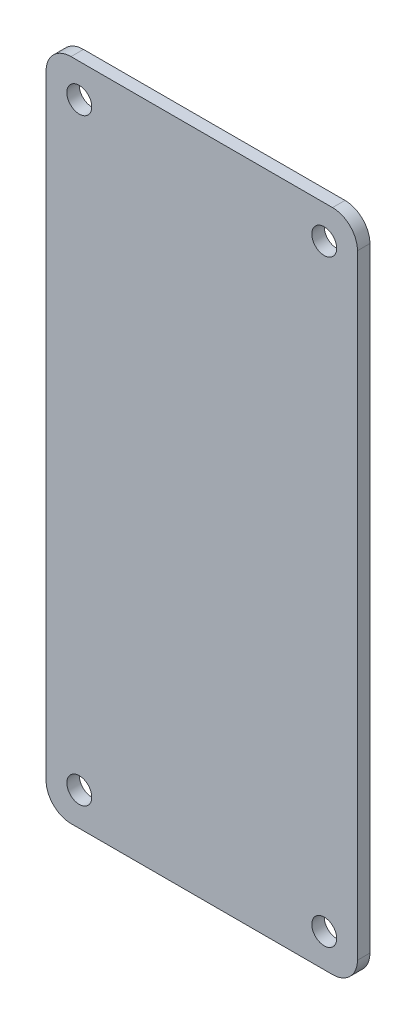
from build123d import *

# Parameters (mm, degrees)
CROQUIS1_W              = 75
CROQUIS1_H              = 160
CROQUIS1_R              = 3
SALIENTE_EXTRUIR1_DEPTH = 3
REDONDEO1_R             = 6


with BuildPart() as part:
    # Croquis1 → Saliente-Extruir1 (new body)
    with BuildSketch(Plane.XY):
        Rectangle(CROQUIS1_W, CROQUIS1_H)
        with Locations((-29.5, 72)):
            Circle(CROQUIS1_R, mode=Mode.SUBTRACT)
        with Locations((29.5, 72)):
            Circle(CROQUIS1_R, mode=Mode.SUBTRACT)
        with Locations((-29.5, -72)):
            Circle(CROQUIS1_R, mode=Mode.SUBTRACT)
        with Locations((29.5, -72)):
            Circle(CROQUIS1_R, mode=Mode.SUBTRACT)
    extrude(amount=SALIENTE_EXTRUIR1_DEPTH)

    # Redondeo1
    redondeo1_edges = [part.edges().sort_by_distance(p)[0] for p in [
        (-37.5, 80, 1.5),
        (37.5, 80, 1.5),
        (37.5, -80, 1.5),
        (-37.5, -80, 1.5),
    ]]
    fillet(redondeo1_edges, radius=REDONDEO1_R)


solid = part.part
